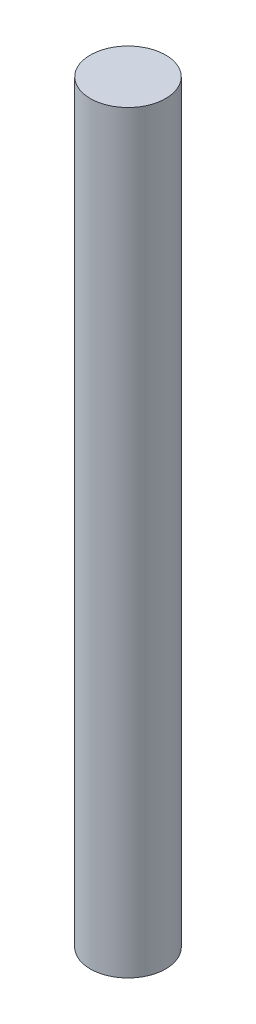
from build123d import *

# Parameters (mm, degrees)
SKETCH1_R           = 0.127
BOSS_EXTRUDE1_DEPTH = 2.54


with BuildPart() as part:
    # Sketch1 → Boss-Extrude1 (new body)
    with BuildSketch(Plane(origin=(0, 0, 0), x_dir=(1, 0, 0), z_dir=(0, 1, 0))):
        Circle(SKETCH1_R)
    extrude(amount=BOSS_EXTRUDE1_DEPTH)


solid = part.part
